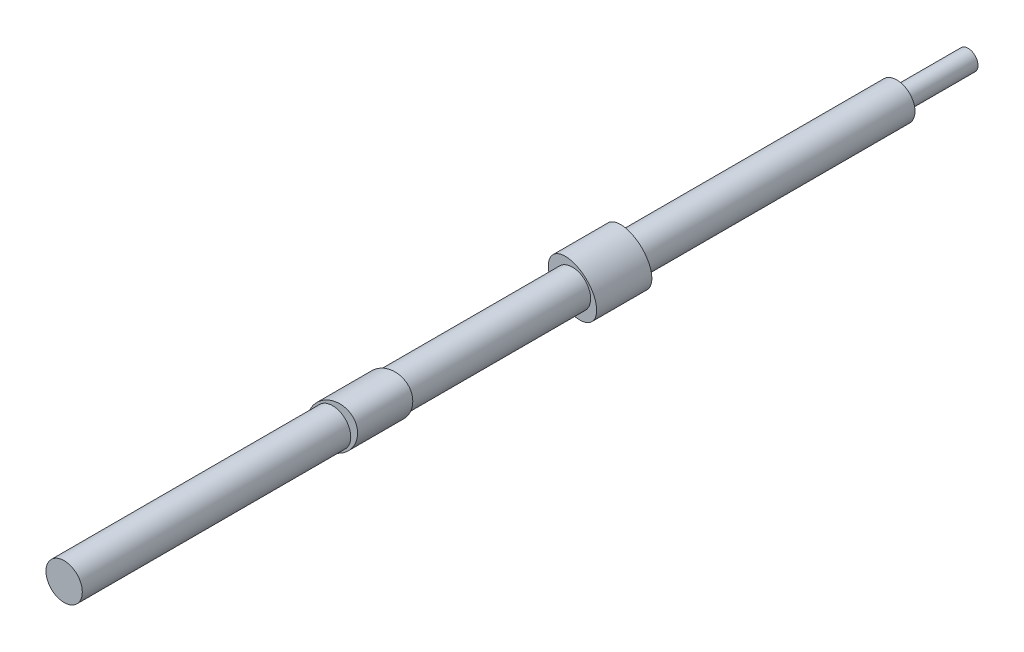
from build123d import *

# Parameters (mm, degrees)
IZIM1_R                     = 3.949830294
Y_KSEKLIK_EKSTR_ZYON1_DEPTH = 90.5
IZIM2_RX                    = 5.99273517
IZIM2_RY                    = 4.41265557
Y_KSEKLIK_EKSTR_ZYON2_DEPTH = 6
IZIM3_RX                    = 5.957724317
IZIM3_RY                    = 4.391576019
Y_KSEKLIK_EKSTR_ZYON3_DEPTH = 6
IZIM5_R                     = 2.152579794
Y_KSEKLIK_EKSTR_ZYON5_DEPTH = 15.5


with BuildPart() as part:
    # Çizim1 → Yükseklik-Ekstrüzyon1 (new body, symmetric)
    with BuildSketch(Plane.XY):
        Circle(IZIM1_R)
    extrude(amount=Y_KSEKLIK_EKSTR_ZYON1_DEPTH, both=True)

    # Çizim2 → Yükseklik-Ekstrüzyon2 (add, symmetric)
    with BuildSketch(Plane.XY.offset(26.14365475)):
        with Locations(Location((0, 0), (0, 0, 38.527816434))):
            Ellipse(IZIM2_RX, IZIM2_RY)
    extrude(amount=Y_KSEKLIK_EKSTR_ZYON2_DEPTH, both=True)

    # Çizim3 → Yükseklik-Ekstrüzyon3 (add, symmetric)
    with BuildSketch(Plane.XY.offset(-26)):
        with Locations(Location((0, 0), (0, 0, 135.642302459))):
            Ellipse(IZIM3_RX, IZIM3_RY)
    extrude(amount=Y_KSEKLIK_EKSTR_ZYON3_DEPTH, both=True)

    # Çizim5 → Yükseklik-Ekstrüzyon5 (add, symmetric)
    with BuildSketch(Plane(origin=(0, 0, -90.5), x_dir=(-1, 0, 0), z_dir=(0, 0, -1))):
        Circle(IZIM5_R)
    extrude(amount=Y_KSEKLIK_EKSTR_ZYON5_DEPTH, both=True)


solid = part.part
